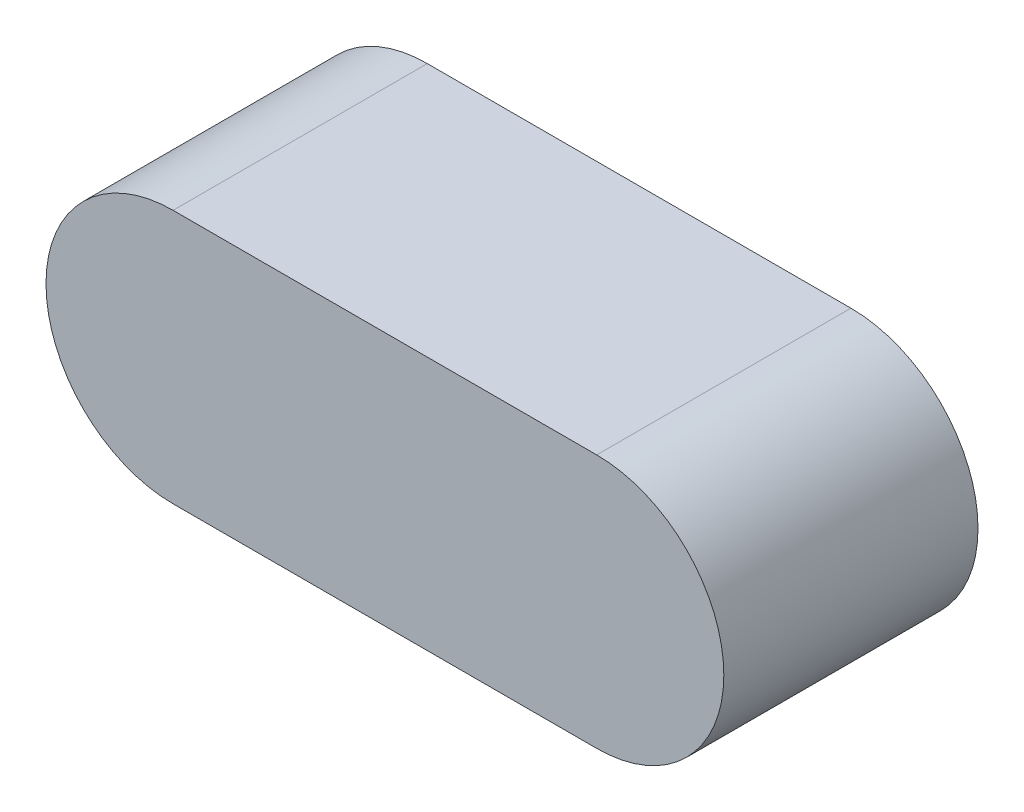
from build123d import *

# Parameters (mm, degrees)
BOSS_EXTRUDE1_DEPTH = 6


with BuildPart() as part:
    # Sketch1 → Boss-Extrude1 (new body)
    with BuildSketch(Plane.XY):
        with BuildLine():
            Line((0, 3), (10, 3))
            ThreePointArc((10, 3), (13, 0), (10, -3))
            Line((10, -3), (0, -3))
            ThreePointArc((0, -3), (-3, 0), (0, 3))
        make_face()
    extrude(amount=BOSS_EXTRUDE1_DEPTH)


solid = part.part
